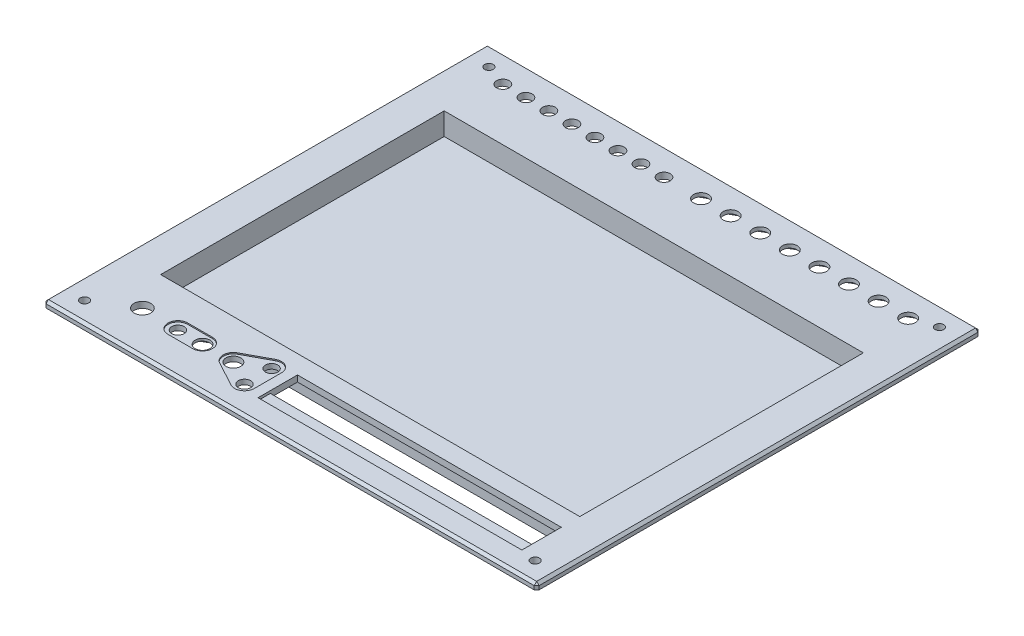
from build123d import *

# Parameters (mm, degrees)
SALIENTE_EXTRUIR1_DEPTH = 200
CROQUIS2_W              = 178
CROQUIS2_H              = 120
SALIENTE_EXTRUIR2_DEPTH = 11
CROQUIS3_W              = 170
CROQUIS3_H              = 115
CORTAR_EXTRUIR1_DEPTH   = 9
CROQUIS4_W              = 2.5
CROQUIS4_H              = 170
CROQUIS4_H_2            = 180
CORTAR_EXTRUIR2_DEPTH   = 42.5
CROQUIS5_R              = 3.075
CORTAR_EXTRUIR3_DEPTH   = 10
CORTAR_EXTRUIR4_DEPTH   = 11.2
CROQUIS7_R              = 2.55
CORTAR_EXTRUIR5_DEPTH   = 10
CROQUIS9_W              = 107
CROQUIS9_H              = 16
CORTAR_EXTRUIR7_DEPTH   = 4
CROQUIS8_R              = 3
CROQUIS8_R_2            = 2.5
CROQUIS8_R_3            = 3.4
CORTAR_EXTRUIR6_DEPTH   = 4
CROQUIS11_OUTSIDE_W     = 256.562
CROQUIS11_OUTSIDE_H     = 236.562
CORTAR_EXTRUIR10_DEPTH  = 1
CORTAR_EXTRUIR11_DEPTH  = 0.5
CROQUIS13_W             = 21.552052497
CROQUIS13_H             = 68.530716877
CROQUIS13_W_2           = 18.933824997
CROQUIS13_H_2           = 79.190643128
CORTAR_EXTRUIR12_DEPTH  = 201
CROQUIS18_R             = 1.75
CORTAR_EXTRUIR13_DEPTH  = 3.5
CROQUIS21_W             = 95.6
CROQUIS21_H             = 8.5
SALIENTE_EXTRUIR3_DEPTH = 5
CROQUIS22_W             = 79.935638501
CROQUIS22_H             = 8.5
SALIENTE_EXTRUIR4_DEPTH = 8
SALIENTE_EXTRUIR5_DEPTH = 107
CROQUIS25_R             = 3
SALIENTE_EXTRUIR6_DEPTH = 1.5
MATRIZL1_COUNT          = 8
MATRIZL1_PITCH          = 12
CHAFL_N1_SIZE           = 1


with BuildPart() as part:
    # Croquis1 → Saliente-Extruir1 (new body)
    with BuildSketch(Plane(origin=(0, 0, 0), x_dir=(0, 0, -1), z_dir=(1, 0, 0))):
        Polygon((-90, 6.926136028), (-90, 45), (90, 45), (90, 6.926136028), (87.7, 5), (87.7, 0), (85.2, 0), (85.2, 6.167243447), (87.5, 8.093379476), (87.5, 42.5), (-87.5, 42.5), (-87.5, 8.093379476), (-85.2, 6.167243447), (-85.2, 0), (-87.7, 0), (-87.7, 5), align=None)
    extrude(amount=SALIENTE_EXTRUIR1_DEPTH)

    # Croquis2 → Saliente-Extruir2 (add)
    with BuildSketch(Plane(origin=(0, 45, 0), x_dir=(1, 0, 0), z_dir=(0, 1, 0))):
        with Locations((100, 0)):
            Rectangle(CROQUIS2_W, CROQUIS2_H)
    extrude(amount=-SALIENTE_EXTRUIR2_DEPTH)

    # Croquis3 → Cortar-Extruir1 (cut)
    with BuildSketch(Plane(origin=(0, 45, 0), x_dir=(1, 0, 0), z_dir=(0, 1, 0))):
        with Locations((100, 0)):
            Rectangle(CROQUIS3_W, CROQUIS3_H)
    extrude(amount=-CORTAR_EXTRUIR1_DEPTH, mode=Mode.SUBTRACT)

    # Croquis4 → Cortar-Extruir2 (cut)
    with BuildSketch(Plane(origin=(0, 0, 0), x_dir=(-1, 0, 0), z_dir=(0, -1, 0))):
        with Locations((-198.75, -5)):
            Rectangle(CROQUIS4_W, CROQUIS4_H)
        with Locations((-1.25, 0)):
            Rectangle(CROQUIS4_W, CROQUIS4_H_2)
    extrude(amount=-CORTAR_EXTRUIR2_DEPTH, mode=Mode.SUBTRACT)

    # Croquis5 → Cortar-Extruir3 (cut)
    with BuildSketch(Plane(origin=(0, 45, 0), x_dir=(1, 0, 0), z_dir=(0, 1, 0))):
        with Locations((181.925, 78.75)):
            Circle(CROQUIS5_R)
        with Locations((169.925, 78.75)):
            Circle(CROQUIS5_R)
        with Locations((157.925, 78.75)):
            Circle(CROQUIS5_R)
        with Locations((145.925, 78.75)):
            Circle(CROQUIS5_R)
        with Locations((133.925, 78.75)):
            Circle(CROQUIS5_R)
        with Locations((121.925, 78.75)):
            Circle(CROQUIS5_R)
        with Locations((109.925, 78.75)):
            Circle(CROQUIS5_R)
        with Locations((97.925, 78.75)):
            Circle(CROQUIS5_R)
    extrude(amount=-CORTAR_EXTRUIR3_DEPTH, mode=Mode.SUBTRACT)

    # Croquis6 → Cortar-Extruir4 (cut)
    with BuildSketch(Plane.XZ.offset(-34)):
        Polygon((185.925, -81.059401077), (185.925, -76.440598923), (181.925, -74.131197846), (177.925, -76.440598923), (177.925, -81.059401077), (181.925, -83.368802154), align=None)
        Polygon((169.925, -74.131197846), (165.925, -76.440598923), (165.925, -81.059401077), (169.925, -83.368802154), (173.925, -81.059401077), (173.925, -76.440598923), align=None)
        Polygon((157.925, -74.131197846), (153.925, -76.440598923), (153.925, -81.059401077), (157.925, -83.368802154), (161.925, -81.059401077), (161.925, -76.440598923), align=None)
        Polygon((145.925, -74.131197846), (141.925, -76.440598923), (141.925, -81.059401077), (145.925, -83.368802154), (149.925, -81.059401077), (149.925, -76.440598923), align=None)
        Polygon((133.925, -74.131197846), (129.925, -76.440598923), (129.925, -81.059401077), (133.925, -83.368802154), (137.925, -81.059401077), (137.925, -76.440598923), align=None)
        Polygon((121.925, -74.131197846), (117.925, -76.440598923), (117.925, -81.059401077), (121.925, -83.368802154), (125.925, -81.059401077), (125.925, -76.440598923), align=None)
        Polygon((109.925, -74.131197846), (105.925, -76.440598923), (105.925, -81.059401077), (109.925, -83.368802154), (113.925, -81.059401077), (113.925, -76.440598923), align=None)
        Polygon((97.925, -74.131197846), (93.925, -76.440598923), (93.925, -81.059401077), (97.925, -83.368802154), (101.925, -81.059401077), (101.925, -76.440598923), align=None)
    extrude(amount=-CORTAR_EXTRUIR4_DEPTH, mode=Mode.SUBTRACT)

    # Croquis7 → Cortar-Extruir5 (cut)
    with BuildSketch(Plane(origin=(0, 45, 0), x_dir=(1, 0, 0), z_dir=(0, 1, 0))):
        with Locations((82.885064516, 78.75)):
            Circle(CROQUIS7_R)
        with Locations((73.551483871, 78.75)):
            Circle(CROQUIS7_R)
        with Locations((64.217903226, 78.75)):
            Circle(CROQUIS7_R)
        with Locations((54.88432258, 78.75)):
            Circle(CROQUIS7_R)
        with Locations((45.550741935, 78.75)):
            Circle(CROQUIS7_R)
        with Locations((36.21716129, 78.75)):
            Circle(CROQUIS7_R)
        with Locations((26.883580645, 78.75)):
            Circle(CROQUIS7_R)
        with Locations((17.55, 78.75)):
            Circle(CROQUIS7_R)
    extrude(amount=-CORTAR_EXTRUIR5_DEPTH, mode=Mode.SUBTRACT)

    # Croquis9 → Cortar-Extruir7 (cut)
    with BuildSketch(Plane(origin=(0, 45, 0), x_dir=(1, 0, 0), z_dir=(0, 1, 0))):
        with Locations((131.5, -73)):
            Rectangle(CROQUIS9_W, CROQUIS9_H)
    extrude(amount=-CORTAR_EXTRUIR7_DEPTH, mode=Mode.SUBTRACT)

    # Croquis8 → Cortar-Extruir6 (cut)
    with BuildSketch(Plane(origin=(0, 45, 0), x_dir=(1, 0, 0), z_dir=(0, 1, 0))):
        with Locations((60, -73)):
            Circle(CROQUIS8_R)
        with Locations((37.5, -73)):
            Circle(CROQUIS8_R_2)
        with Locations((23.1, -73)):
            Circle(CROQUIS8_R_3)
        with Locations((47.5, -73)):
            Circle(CROQUIS8_R)
        with Locations((70, -78.5)):
            Circle(CROQUIS8_R_2)
        with Locations((70, -67.5)):
            Circle(CROQUIS8_R_2)
    extrude(amount=-CORTAR_EXTRUIR6_DEPTH, mode=Mode.SUBTRACT)

    # Croquis11 outside → Cortar-Extruir10 (cut)
    with BuildSketch(Plane.XZ.offset(-42.5)):
        with Locations((100, 0)):
            Rectangle(CROQUIS11_OUTSIDE_W, CROQUIS11_OUTSIDE_H)
        Polygon((47.5, 4691.358777844), (-3952.116025404, 2382.179388922), (-3952.116025404, -2236.179388922), (47.5, -4545.358777844), (4047.116025404, -2236.179388922), (4047.116025404, 2382.179388922), align=None, mode=Mode.SUBTRACT)
        Polygon((47.5, 68.381197846), (51.5, 70.690598923), (51.5, 75.309401077), (47.5, 77.618802154), (43.5, 75.309401077), (43.5, 70.690598923), align=None)
    extrude(amount=-CORTAR_EXTRUIR10_DEPTH, mode=Mode.SUBTRACT)

    # Croquis12 → Cortar-Extruir11 (cut)
    with BuildSketch(Plane(origin=(0, 45, 0), x_dir=(1, 0, 0), z_dir=(0, 1, 0))):
        with BuildLine():
            Line((68.102067459, -82.021058373), (58.056221043, -76.606112981))
            ThreePointArc((58.056221043, -76.606112981), (55.903376089, -73), (58.056221043, -69.393887019))
            Line((58.056221043, -69.393887019), (68.102067459, -63.978941627))
            ThreePointArc((68.102067459, -63.978941627), (72.050398722, -64.065489106), (74, -67.5))
            Line((74, -67.5), (74, -78.5))
            ThreePointArc((74, -78.5), (72.050398722, -81.934510894), (68.102067459, -82.021058373))
        make_face()
        with BuildLine():
            Line((47.5, -77), (37.5, -77))
            ThreePointArc((37.5, -77), (33.5, -73), (37.5, -69))
            Line((37.5, -69), (47.5, -69))
            ThreePointArc((47.5, -69), (51.5, -73), (47.5, -77))
        make_face()
    extrude(amount=-CORTAR_EXTRUIR11_DEPTH, mode=Mode.SUBTRACT)

    # Croquis13 → Cortar-Extruir12 (cut, through all)
    with BuildSketch(Plane.ZY):
        with Locations((-79.223973752, 8.234641561)):
            Rectangle(CROQUIS13_W, CROQUIS13_H)
        with Locations((80.533087502, 2.904678436)):
            Rectangle(CROQUIS13_W_2, CROQUIS13_H_2)
    extrude(amount=-CORTAR_EXTRUIR12_DEPTH, mode=Mode.SUBTRACT)

    # Croquis18 → Cortar-Extruir13 (cut, through all)
    with BuildSketch(Plane.XZ.offset(-42.5)):
        with Locations((191.36, -82)):
            Circle(CROQUIS18_R)
        with Locations((8.64, -82)):
            Circle(CROQUIS18_R)
        with Locations((8.64, 82)):
            Circle(CROQUIS18_R)
        with Locations((191.36, 82)):
            Circle(CROQUIS18_R)
    extrude(amount=-CORTAR_EXTRUIR13_DEPTH, mode=Mode.SUBTRACT)

    # Croquis21 → Saliente-Extruir3 (add)
    with BuildSketch(Plane(origin=(0, 0, -60), x_dir=(-1, 0, 0), z_dir=(0, 0, -1))):
        with Locations((-58.8, 38.25)):
            Rectangle(CROQUIS21_W, CROQUIS21_H)
    extrude(amount=SALIENTE_EXTRUIR3_DEPTH)

    # Croquis22 → Saliente-Extruir4 (add)
    with BuildSketch(Plane.ZY.offset(-11)):
        with Locations((-25.03218075, 38.25)):
            Rectangle(CROQUIS22_W, CROQUIS22_H)
    extrude(amount=SALIENTE_EXTRUIR4_DEPTH)

    # Croquis24 → Saliente-Extruir5 (add)
    with BuildSketch(Plane(origin=(78, 0, 0), x_dir=(0, 0, -1), z_dir=(1, 0, 0))):
        Polygon((-84.5, 42.5), (-83, 41), (-76, 41), (-76, 44), (-80, 44), (-81, 45), (-81, 42.5), align=None)
    extrude(amount=SALIENTE_EXTRUIR5_DEPTH)

    # Croquis25 → Saliente-Extruir6 (add)
    with BuildSketch(Plane(origin=(0, 45, 0), x_dir=(1, 0, 0), z_dir=(0, 1, 0))):
        Polygon((181.925, 74.131197846), (185.925, 76.440598923), (185.925, 81.059401077), (181.925, 83.368802154), (177.925, 81.059401077), (177.925, 76.440598923), align=None)
        with Locations((181.925, 78.75)):
            Circle(CROQUIS25_R, mode=Mode.SUBTRACT)
    saliente_extruir6 = extrude(amount=-SALIENTE_EXTRUIR6_DEPTH)

    # MatrizL1: Saliente-Extruir6 ×8
    with Locations(*[(-i * MATRIZL1_PITCH, 0, 0) for i in range(1, MATRIZL1_COUNT)]):
        add(saliente_extruir6)

    # Chaflán1
    chafl_n1_edges = [part.edges().sort_by_distance(p)[0] for p in [
        (0, 43.75, 90),
        (0, 45, 0),
        (0, 43.75, -90),
        (100, 45, 90),
        (100, 45, -90),
        (200, 43.75, -90),
        (200, 45, 0),
        (200, 43.75, 90),
    ]]
    chamfer(chafl_n1_edges, length=CHAFL_N1_SIZE)


solid = part.part
